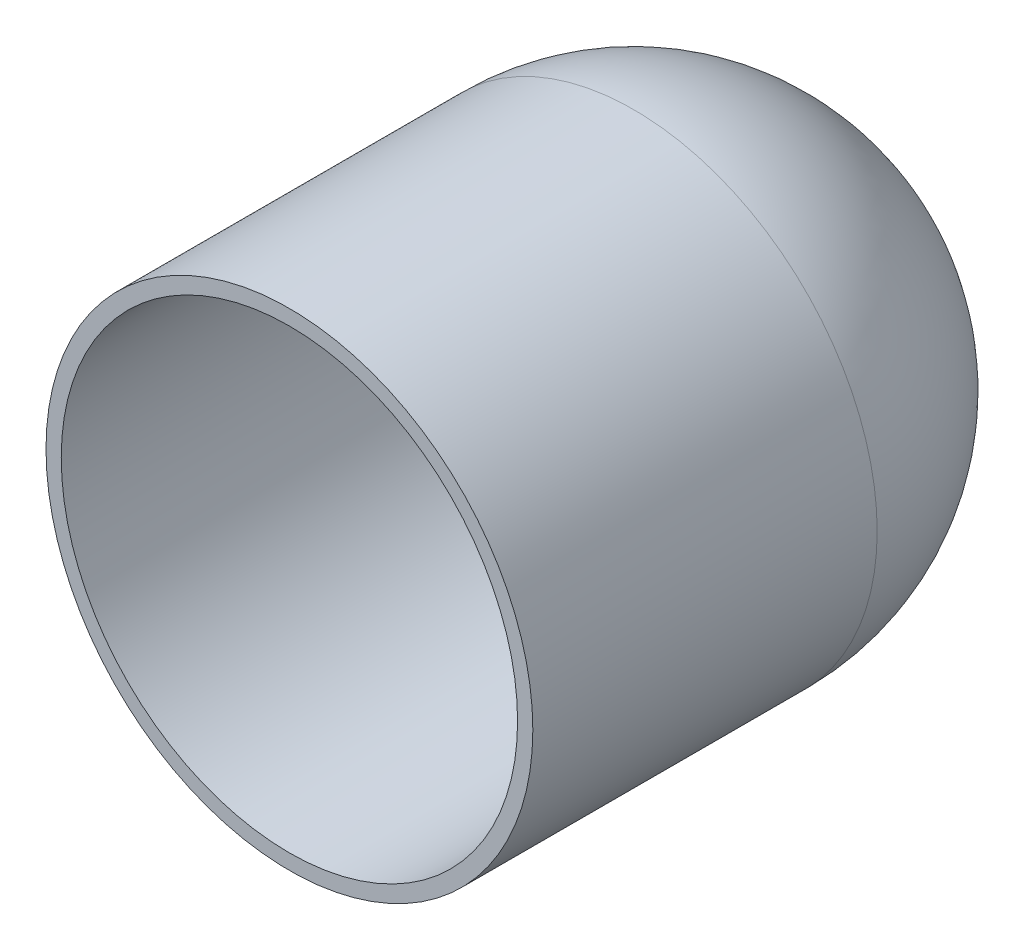
from build123d import *

# Parameters (mm, degrees)
SKETCH1_R           = 22.62
BOSS_EXTRUDE1_DEPTH = 32
SKETCH3_R           = 5.673095137
CUT_EXTRUDE1_DEPTH  = 76
SKETCH5_R           = 21.203687462
CUT_EXTRUDE2_DEPTH  = 31


with BuildPart() as part:
    # Sketch1 → Boss-Extrude1 (new body)
    with BuildSketch(Plane.XY):
        Circle(SKETCH1_R)
    extrude(amount=BOSS_EXTRUDE1_DEPTH)

    # Sketch2 one side → Revolve1 (revolve)
    with BuildSketch(Plane(origin=(0, 0, 0), x_dir=(-1, 0, 0), z_dir=(0, 0, -1))):
        with BuildLine():
            ThreePointArc((0, 22.62), (-22.62, 0), (0, -22.62))
            Line((0, -22.62), (0, 0))
            Line((0, 0), (0, 22.62))
        make_face()
    revolve(axis=Axis((0, 0, 0), (0, 1, 0)))

    # Sketch3 → Cut-Extrude1 (cut)
    with BuildSketch(Plane.XY.offset(32)):
        Circle(SKETCH3_R)
    extrude(amount=-CUT_EXTRUDE1_DEPTH, mode=Mode.SUBTRACT)

    # Sketch5 → Cut-Extrude2 (cut)
    with BuildSketch(Plane.XY.offset(32)):
        Circle(SKETCH5_R)
    extrude(amount=-CUT_EXTRUDE2_DEPTH, mode=Mode.SUBTRACT)


solid = part.part
